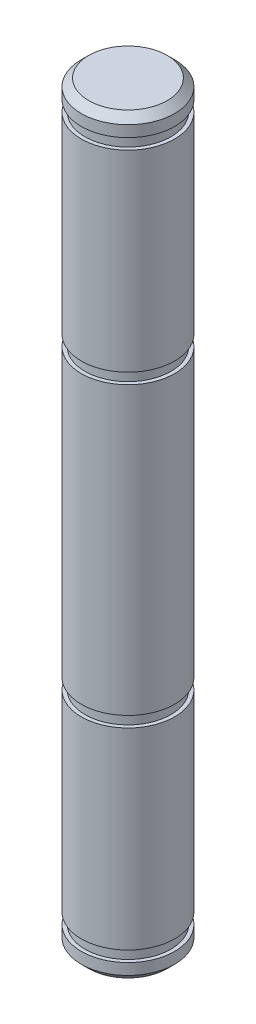
from build123d import *

# Parameters (mm, degrees)
CHAMFER1_SIZE = 0.508


with BuildPart() as part:
    # Sketch1 → Revolve1 (revolve)
    with BuildSketch(Plane.XY):
        Polygon((-3.175, 23.5585), (-3.175, 10.4775), (-2.921, 10.4775), (-2.921, 9.7409), (-3.175, 9.7409), (-3.175, -9.7409), (-2.921, -9.7409), (-2.921, -10.4775), (-3.175, -10.4775), (-3.175, -23.5585), (-2.921, -23.5585), (-2.921, -24.2951), (-3.175, -24.2951), (-3.175, -25.5651), (0, -25.5651), (0, 25.5651), (-3.175, 25.5651), (-3.175, 24.2951), (-2.921, 24.2951), (-2.921, 23.5585), align=None)
    revolve(axis=Axis((0, 25.5651, 0), (0, -1, 0)))

    # Chamfer1
    chamfer1_edges = [part.edges().sort_by_distance(p)[0] for p in [
        (3.175, -25.5651, 0),
        (3.175, 25.5651, 0),
    ]]
    chamfer(chamfer1_edges, length=CHAMFER1_SIZE)


solid = part.part
